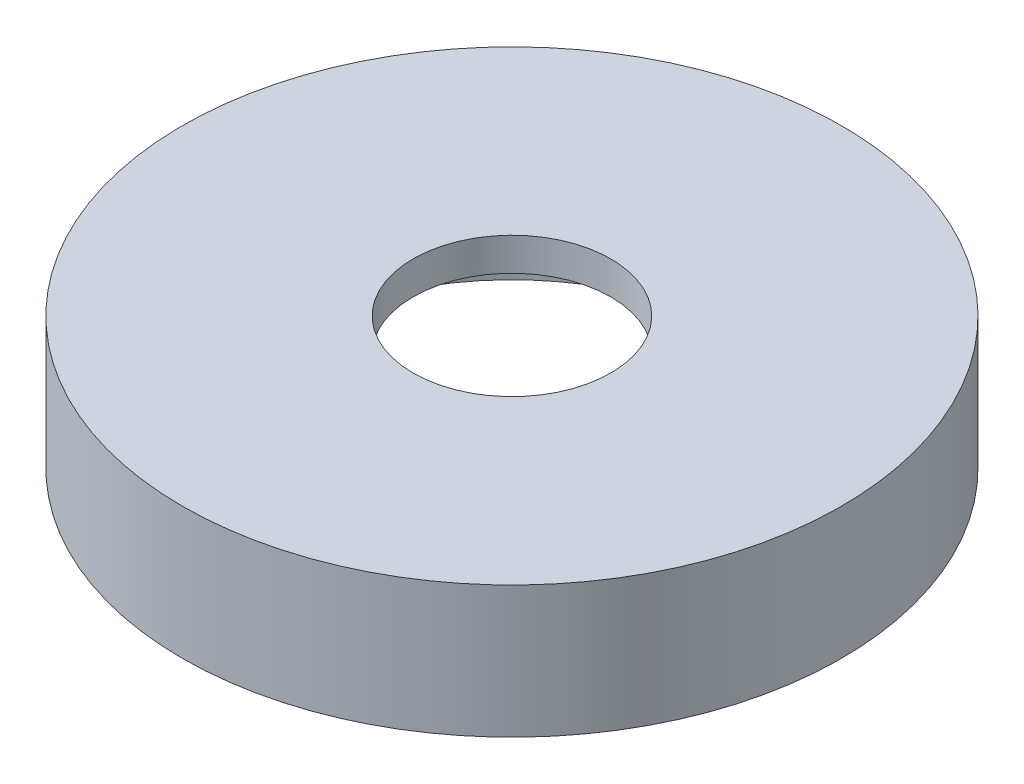
from build123d import *

# Parameters (mm, degrees)
SKETCH1_R                 = 20
BOSS_EXTRUDE1_DEPTH       = 8
SKETCH2_R                 = 14
CUT_EXTRUDE1_DEPTH        = 6
CUT_EXTRUDE4_REACH        = 10
SKETCH3_R                 = 6
M3X0_5_TAPPED_HOLE1_D     = 2.5
M3X0_5_TAPPED_HOLE1_DEPTH = 4
M3X0_5_TAPPED_HOLE1_TIP   = 0.751075774


with BuildPart() as part:
    # Sketch1 → Boss-Extrude1 (new body)
    with BuildSketch(Plane(origin=(0, 3, 0), x_dir=(1, 0, 0), z_dir=(0, 1, 0))):
        with Locations((-34.143225555, -5.12970783)):
            Circle(SKETCH1_R)
    extrude(amount=BOSS_EXTRUDE1_DEPTH)

    # Sketch2 → Cut-Extrude1 (cut)
    with BuildSketch(Plane.XZ.offset(-3)):
        with Locations((-34.143225555, 5.12970783)):
            Circle(SKETCH2_R)
    extrude(amount=-CUT_EXTRUDE1_DEPTH, mode=Mode.SUBTRACT)

    # Sketch3 → Cut-Extrude4 (cut, up to next)
    with BuildSketch(Plane(origin=(0, 11, 0), x_dir=(1, 0, 0), z_dir=(0, 1, 0)), mode=Mode.PRIVATE) as cut_extrude4_sk1:
        with Locations((-34.143225555, -5.12970783)):
            Circle(SKETCH3_R)
    cut_extrude4_tool1 = extrude(cut_extrude4_sk1.sketch, amount=-CUT_EXTRUDE4_REACH, mode=Mode.PRIVATE) & part.part
    add(cut_extrude4_tool1.solids().sort_by_distance((-34.143226, 11, 5.129708))[0], mode=Mode.SUBTRACT)

    # M3x0.5 Tapped Hole1
    with Locations(Plane.XZ.offset(-3)):
        with Locations((-25.643225555, 19.852139695), (-51.143225555, 5.12970783), (-25.643225555, -9.592724034)):
            Hole(M3X0_5_TAPPED_HOLE1_D / 2, depth=M3X0_5_TAPPED_HOLE1_DEPTH)
            with Locations((0, 0, -(M3X0_5_TAPPED_HOLE1_DEPTH + M3X0_5_TAPPED_HOLE1_TIP / 2))):  # 118° drill point
                Cone(0, M3X0_5_TAPPED_HOLE1_D / 2, M3X0_5_TAPPED_HOLE1_TIP, mode=Mode.SUBTRACT)


solid = part.part
